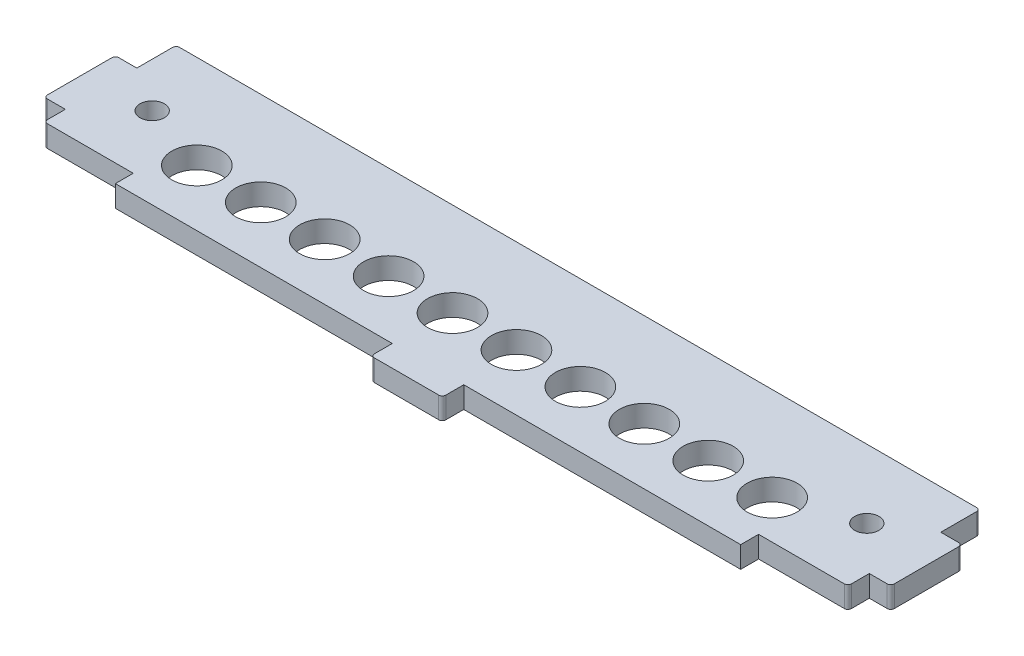
from build123d import *

# Parameters (mm, degrees)
SKETCH_1_R            = 3.5
SKETCH_1_W            = 10
SKETCH_1_H            = 3
EXTRUDE_1_DEPTH       = 3
HOLE_WIZARD_M31_D     = 3.4
HOLE_WIZARD_M31_DEPTH = 10
HOLE_WIZARD_M31_TIP   = 1.021463052
FILLET_1_R            = 0.5
FILLET_2_R            = 0.5


with BuildPart() as part:
    # Эскиз1 → Бобышка-Вытянуть1 (new body)
    with BuildSketch(Plane(origin=(0, 0, 0), x_dir=(1, 0, 0), z_dir=(0, 1, 0))):
        Polygon((-43.75, -21), (43.75, -21), (43.75, -18.5), (56.25, -18.5), (56.25, -15.5), (59.25, -15.5), (59.25, -5.5), (56.25, -5.5), (56.25, 0), (-56.25, 0), (-56.25, -5.5), (-59.25, -5.5), (-59.25, -15.5), (-56.25, -15.5), (-56.25, -18.5), (-43.75, -18.5), align=None)
        with Locations((-40.25, -13.1)):
            Circle(SKETCH_1_R, mode=Mode.SUBTRACT)
        with Locations((-31.305555556, -13.1)):
            Circle(SKETCH_1_R, mode=Mode.SUBTRACT)
        with Locations((-22.361111111, -13.1)):
            Circle(SKETCH_1_R, mode=Mode.SUBTRACT)
        with Locations((-13.416666667, -13.1)):
            Circle(SKETCH_1_R, mode=Mode.SUBTRACT)
        with Locations((-4.472222222, -13.1)):
            Circle(SKETCH_1_R, mode=Mode.SUBTRACT)
        with Locations((4.472222222, -13.1)):
            Circle(SKETCH_1_R, mode=Mode.SUBTRACT)
        with Locations((13.416666667, -13.1)):
            Circle(SKETCH_1_R, mode=Mode.SUBTRACT)
        with Locations((22.361111111, -13.1)):
            Circle(SKETCH_1_R, mode=Mode.SUBTRACT)
        with Locations((31.305555556, -13.1)):
            Circle(SKETCH_1_R, mode=Mode.SUBTRACT)
        with Locations((40.25, -13.1)):
            Circle(SKETCH_1_R, mode=Mode.SUBTRACT)
        with Locations((0, -22.5)):
            Rectangle(SKETCH_1_W, SKETCH_1_H)
    extrude(amount=EXTRUDE_1_DEPTH)

    # Отверстие с зазором M31
    with Locations(Plane(origin=(0, 3, 0), x_dir=(1, 0, 0), z_dir=(0, 1, 0))):
        with Locations((50, -9.6), (-50, -9.6)):
            Hole(HOLE_WIZARD_M31_D / 2, depth=HOLE_WIZARD_M31_DEPTH)
            with Locations((0, 0, -(HOLE_WIZARD_M31_DEPTH + HOLE_WIZARD_M31_TIP / 2))):  # 118° drill point
                Cone(0, HOLE_WIZARD_M31_D / 2, HOLE_WIZARD_M31_TIP, mode=Mode.SUBTRACT)

    # Скругление1
    fillet_1_edges = [part.edges().sort_by_distance(p)[0] for p in [
        (-59.25, 1.5, 15.5),
        (-59.25, 1.5, 5.5),
        (59.25, 1.5, 5.5),
        (59.25, 1.5, 15.5),
    ]]
    fillet(fillet_1_edges, radius=FILLET_1_R)

    # Скругление2
    fillet_2_edges = [part.edges().sort_by_distance(p)[0] for p in [
        (-56.25, 1.5, 18.5),
        (-56.25, 1.5, 0),
        (56.25, 1.5, 0),
        (56.25, 1.5, 18.5),
        (5, 1.5, 24),
        (-5, 1.5, 24),
    ]]
    fillet(fillet_2_edges, radius=FILLET_2_R)


solid = part.part
